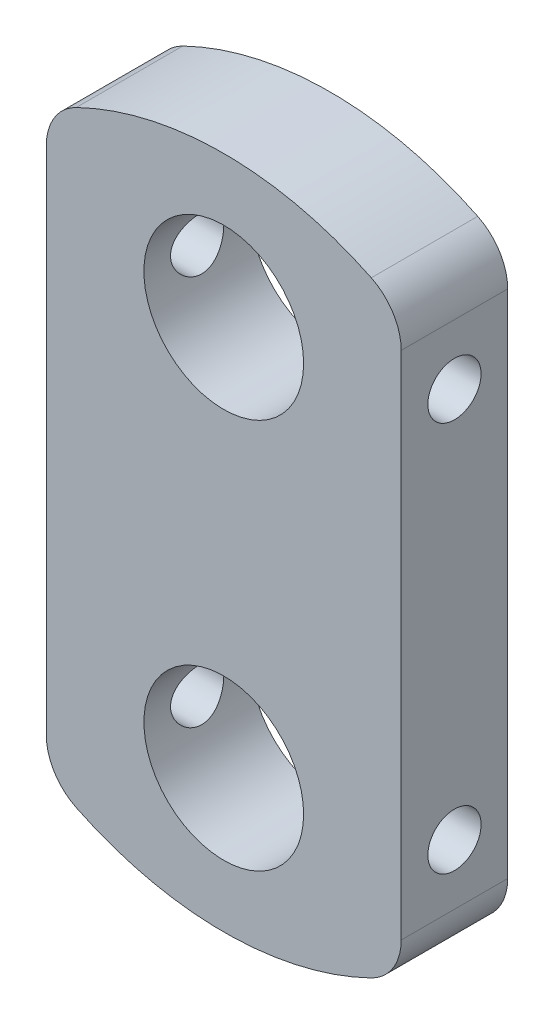
from build123d import *

# Parameters (mm, degrees)
SKETCH1_R               = 4.5
SKETCH1_R_2             = 3
BOSS_EXTRUDE1_DEPTH     = 6
SKETCH2_R               = 1.5
CUT_EXTRUDE1_DEPTH      = 1
CUT_EXTRUDE1_DEPTH_BACK = 21


with BuildPart() as part:
    # Sketch1 → Boss-Extrude1 (new body)
    with BuildSketch(Plane.XY):
        with BuildLine():
            Line((-10, 0), (0, 0))
            Line((0, 0), (10, 0))
            Line((10, 0), (10, 14.38749457))
            ThreePointArc((10, 14.38749457), (4.456626225, 12.796504363), (8.312500108, 17.085149749))
            ThreePointArc((8.312500108, 17.085149749), (2.5e-08, 19), (-8.312500062, 17.085149771))
            ThreePointArc((-8.312500062, 17.085149771), (-5.409009772, 16.930868332), (-4, 14.38749457))
            ThreePointArc((-4, 14.38749457), (-7, 11.38749457), (-10, 14.38749457))
            Line((-10, 14.38749457), (-10, 0))
        make_face()
        with Locations((0, 11)):
            Circle(SKETCH1_R, mode=Mode.SUBTRACT)
        with Locations((7, 14.38749457)):
            Circle(SKETCH1_R_2)
        with Locations((-7, 14.38749457)):
            Circle(SKETCH1_R_2)
        with BuildLine():
            Line((10, 0), (0, 0))
            Line((0, 0), (-10, 0))
            Line((-10, 0), (-10, -14.38749457))
            ThreePointArc((-10, -14.38749457), (-7, -11.38749457), (-4, -14.38749457))
            ThreePointArc((-4, -14.38749457), (-5.409009694, -16.930868283), (-8.312499897, -17.085149852))
            ThreePointArc((-8.312499897, -17.085149852), (9.1e-08, -19), (8.312500061, -17.085149772))
            ThreePointArc((8.312500061, -17.085149772), (4.456626238, -12.796504341), (10, -14.38749457))
            Line((10, -14.38749457), (10, 0))
        make_face()
        with Locations((0, -11)):
            Circle(SKETCH1_R, mode=Mode.SUBTRACT)
        with Locations((-7, -14.38749457)):
            Circle(SKETCH1_R_2)
        with Locations((7, -14.38749457)):
            Circle(SKETCH1_R_2)
    extrude(amount=BOSS_EXTRUDE1_DEPTH)

    # Sketch2 → Cut-Extrude1 (cut, two sides)
    with BuildSketch(Plane(origin=(10, 0, 0), x_dir=(0, 0, -1), z_dir=(1, 0, 0))) as cut_extrude1_sk:
        with Locations((-3, 11)):
            Circle(SKETCH2_R)
        with Locations((-3, -11)):
            Circle(SKETCH2_R)
    extrude(amount=CUT_EXTRUDE1_DEPTH, mode=Mode.SUBTRACT)
    extrude(cut_extrude1_sk.sketch, amount=-CUT_EXTRUDE1_DEPTH_BACK, mode=Mode.SUBTRACT)


solid = part.part
